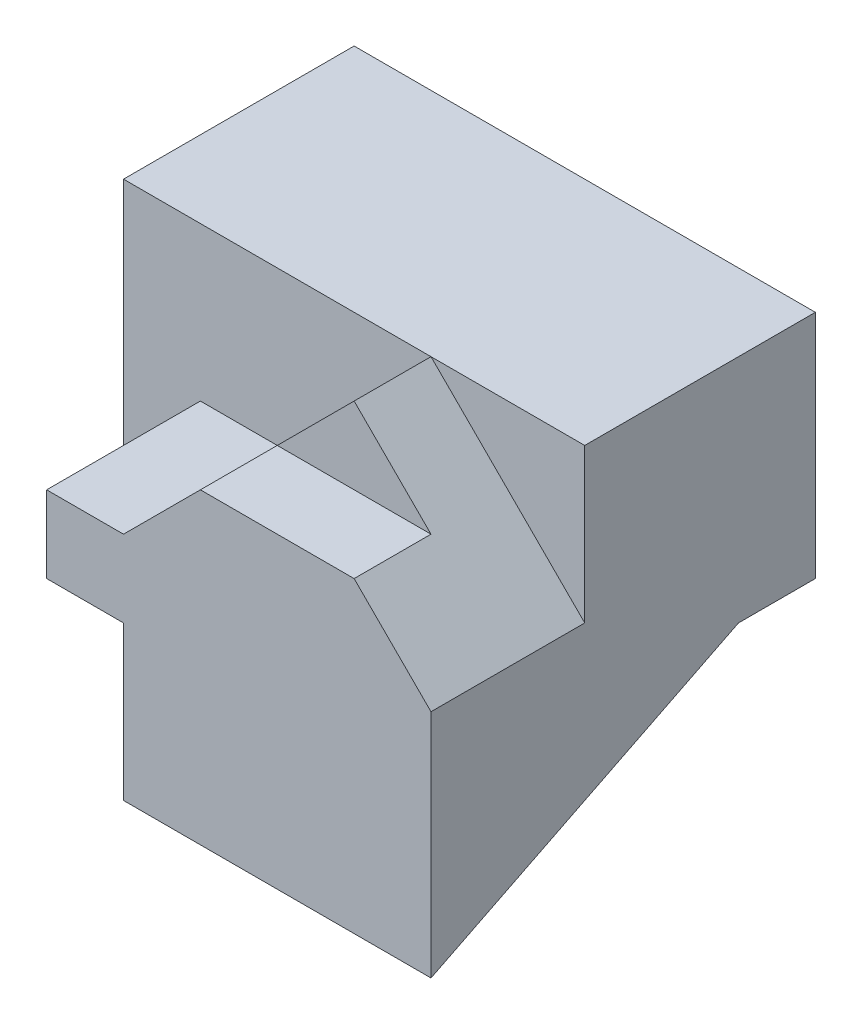
from build123d import *

# Parameters (mm, degrees)
SKETCH1_W           = 6
SKETCH1_H           = 5
BOSS_EXTRUDE1_DEPTH = 5
CUT_EXTRUDE1_DEPTH  = 2
CUT_EXTRUDE2_DEPTH  = 2
SKETCH5_W           = 1
SKETCH5_H           = 2
CUT_EXTRUDE3_DEPTH  = 5
CUT_EXTRUDE4_DEPTH  = 2
CUT_EXTRUDE5_DEPTH  = 2
CUT_EXTRUDE6_DEPTH  = 1


with BuildPart() as part:
    # Sketch1 → Boss-Extrude1 (new body)
    with BuildSketch(Plane.XY):
        with Locations((3, 2.5)):
            Rectangle(SKETCH1_W, SKETCH1_H)
    extrude(amount=BOSS_EXTRUDE1_DEPTH)

    # Sketch2 → Cut-Extrude1 (cut)
    with BuildSketch(Plane(origin=(6, 0, 0), x_dir=(0, 0, -1), z_dir=(1, 0, 0))):
        Polygon((0, 2), (-1, 2), (-5, 0), (0, 0), align=None)
    extrude(amount=-CUT_EXTRUDE1_DEPTH, mode=Mode.SUBTRACT)

    # Sketch4 → Cut-Extrude2 (cut)
    with BuildSketch(Plane.ZY):
        Polygon((1, 0), (5, 2), (5, 0), align=None)
    extrude(amount=-CUT_EXTRUDE2_DEPTH, mode=Mode.SUBTRACT)

    # Sketch5 → Cut-Extrude3 (cut)
    with BuildSketch(Plane(origin=(0, 5, 0), x_dir=(1, 0, 0), z_dir=(0, 1, 0))):
        with Locations((0.5, -4)):
            Rectangle(SKETCH5_W, SKETCH5_H)
    extrude(amount=-CUT_EXTRUDE3_DEPTH, mode=Mode.SUBTRACT)

    # Sketch6 → Cut-Extrude4 (cut)
    with BuildSketch(Plane.XY.offset(5)):
        Polygon((4, 5), (6, 3), (6, 5), align=None)
    extrude(amount=-CUT_EXTRUDE4_DEPTH, mode=Mode.SUBTRACT)

    # Sketch7 → Cut-Extrude5 (cut)
    with BuildSketch(Plane.XY.offset(5)):
        Polygon((4, 5), (2, 3), (1, 3), (1, 5), align=None)
    extrude(amount=-CUT_EXTRUDE5_DEPTH, mode=Mode.SUBTRACT)

    # Sketch8 → Cut-Extrude6 (cut)
    with BuildSketch(Plane.XY.offset(5)):
        Polygon((3, 4), (5, 4), (4, 5), align=None)
    extrude(amount=-CUT_EXTRUDE6_DEPTH, mode=Mode.SUBTRACT)


solid = part.part
